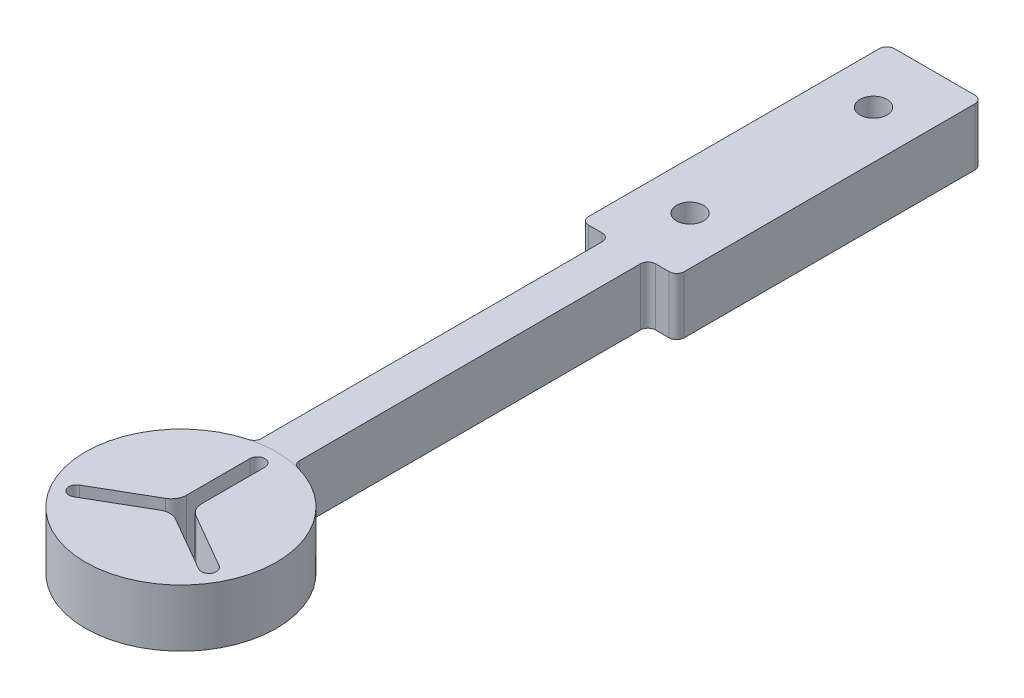
from build123d import *

# Parameters (mm, degrees)
BOSS_EXTRUDE1_DEPTH = 9.525
SKETCH2_R           = 2.2479
CUT_EXTRUDE1_DEPTH  = 93.175319142
CUT_EXTRUDE2_DEPTH  = 93.175319142
FILLET1_R           = 1.25
FILLET2_R           = 2.54


with BuildPart() as part:
    # Sketch1 → Boss-Extrude1 (new body)
    with BuildSketch(Plane(origin=(0, 0, 0), x_dir=(1, 0, 0), z_dir=(0, 1, 0))):
        with BuildLine():
            Line((-7.9375, 50.8), (7.9375, 50.8))
            Line((7.9375, 50.8), (7.9375, 0))
            Line((7.9375, 0), (3.175, 0))
            Line((3.175, 0), (3.175, -58.867740133))
            ThreePointArc((3.175, -58.867740133), (0, -90.297), (-3.175, -58.867740133))
            Line((-3.175, -58.867740133), (-3.175, 0))
            Line((-3.175, 0), (-7.9375, 0))
            Line((-7.9375, 0), (-7.9375, 50.8))
        make_face()
    extrude(amount=BOSS_EXTRUDE1_DEPTH)

    # Sketch2 → Cut-Extrude1 (cut, through all)
    with BuildSketch(Plane(origin=(0, 9.525, 0), x_dir=(1, 0, 0), z_dir=(0, 1, 0))):
        with Locations((0, 40.64)):
            Circle(SKETCH2_R)
        with Locations((0, 10.16)):
            Circle(SKETCH2_R)
    extrude(amount=-CUT_EXTRUDE1_DEPTH, mode=Mode.SUBTRACT)

    # Sketch3 → Cut-Extrude2 (cut, through all)
    with BuildSketch(Plane(origin=(0, 9.525, 0), x_dir=(1, 0, 0), z_dir=(0, 1, 0))):
        with BuildLine():
            Line((0, -75.85914029), (10.376222628, -81.849855218))
            ThreePointArc((10.376222628, -81.849855218), (12.076377846, -81.3943), (11.620822628, -79.694144782))
            Line((11.620822628, -79.694144782), (1.2446, -73.703429855))
            Line((1.2446, -73.703429855), (1.2446, -61.722))
            ThreePointArc((1.2446, -61.722), (0, -60.4774), (-1.2446, -61.722))
            Line((-1.2446, -61.722), (-1.2446, -73.703429855))
            Line((-1.2446, -73.703429855), (-11.620822628, -79.694144782))
            ThreePointArc((-11.620822628, -79.694144782), (-12.076377846, -81.3943), (-10.376222628, -81.849855218))
            Line((-10.376222628, -81.849855218), (0, -75.85914029))
        make_face()
    extrude(amount=-CUT_EXTRUDE2_DEPTH, mode=Mode.SUBTRACT)

    # Fillet1
    fillet1_edges = [part.edges().sort_by_distance(p)[0] for p in [
        (7.9375, 4.7625, -50.8),
        (-7.9375, 4.7625, -50.8),
        (-7.9375, 4.7625, 0),
        (-3.175, 4.7625, 0),
        (7.9375, 4.7625, 0),
        (3.175, 4.7625, 0),
        (3.175, 4.7625, 58.867740133),
        (-3.175, 4.7625, 58.867740133),
    ]]
    fillet(fillet1_edges, radius=FILLET1_R)

    # Fillet2
    fillet2_edges = [part.edges().sort_by_distance(p)[0] for p in [
        (0, 4.7625, 75.85914029),
        (1.2446, 4.7625, 73.703429855),
        (-1.2446, 4.7625, 73.703429855),
    ]]
    fillet(fillet2_edges, radius=FILLET2_R)


solid = part.part
